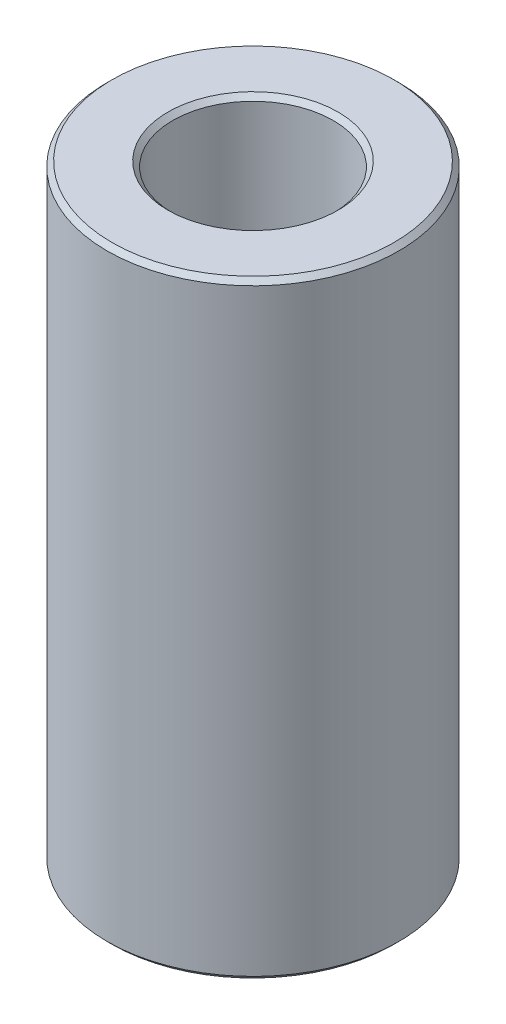
from build123d import *

# Parameters (mm, degrees)
SKETCH1_R            = 6
BOSS_EXTRUDE1_DEPTH  = 25
M6_CLEARANCE_HOLE1_D = 6.6
CHAMFER1_SIZE        = 0.2


with BuildPart() as part:
    # Sketch1 → Boss-Extrude1 (new body)
    with BuildSketch(Plane(origin=(0, 0, 0), x_dir=(1, 0, 0), z_dir=(0, 1, 0))):
        Circle(SKETCH1_R)
    extrude(amount=BOSS_EXTRUDE1_DEPTH)

    # M6 Clearance Hole1 (through all)
    with Locations(Plane(origin=(0, 25, 0), x_dir=(1, 0, 0), z_dir=(0, 1, 0))):
        with Locations((0, 0)):
            Hole(M6_CLEARANCE_HOLE1_D / 2)

    # Chamfer1
    chamfer1_edges = [part.edges().sort_by_distance(p)[0] for p in [
        (-6, 0, 0),
        (-6, 25, 0),
        (3.3, 25, 0),
        (3.3, 0, 0),
    ]]
    chamfer(chamfer1_edges, length=CHAMFER1_SIZE)


solid = part.part
